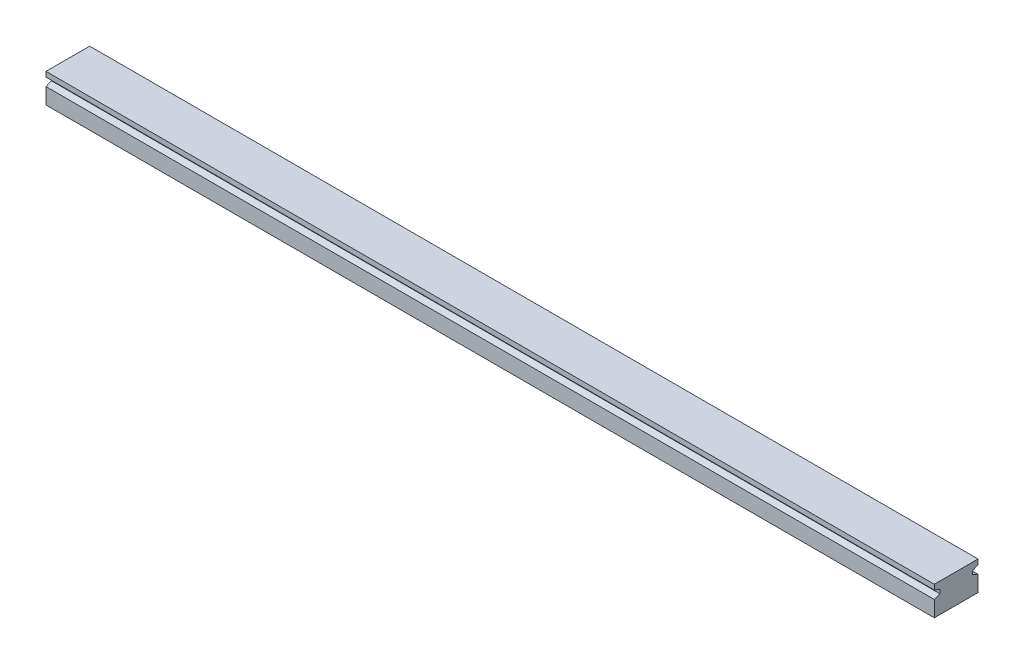
from build123d import *

# Parameters (mm, degrees)
SKETCH2_W           = 280
SKETCH2_H           = 12
SKETCH2_R           = 2
BOSS_EXTRUDE1_DEPTH = 4
CUT_EXTRUDE1_DEPTH  = 281
SKETCH5_R           = 2
BOSS_EXTRUDE2_DEPTH = 2
SKETCH4_W           = 18
SKETCH4_H           = 12
CUT_EXTRUDE2_DEPTH  = 9
BOSS_EXTRUDE3_REACH = 10
SKETCH7_R           = 2
SKETCH8_R           = 2
SKETCH8_R_2         = 1.5
BOSS_EXTRUDE4_DEPTH = 2


with BuildPart() as part:
    # Sketch2 → Boss-Extrude1 (new body, symmetric)
    with BuildSketch(Plane(origin=(0, 0, 0), x_dir=(1, 0, 0), z_dir=(0, 1, 0))):
        Rectangle(SKETCH2_W, SKETCH2_H)
        with Locations((-125, 0)):
            Circle(SKETCH2_R, mode=Mode.SUBTRACT)
        with Locations((-75, 0)):
            Circle(SKETCH2_R, mode=Mode.SUBTRACT)
        with Locations((-25, 0)):
            Circle(SKETCH2_R, mode=Mode.SUBTRACT)
        with Locations((25, 0)):
            Circle(SKETCH2_R, mode=Mode.SUBTRACT)
        with Locations((75, 0)):
            Circle(SKETCH2_R, mode=Mode.SUBTRACT)
        with Locations((125, 0)):
            Circle(SKETCH2_R, mode=Mode.SUBTRACT)
    extrude(amount=BOSS_EXTRUDE1_DEPTH, both=True)

    # Sketch3 → Cut-Extrude1 (cut, through all)
    with BuildSketch(Plane.ZY.offset(140)):
        Polygon((-6, 2.625), (-6, 0.375), (-4.5, 1), (-4.5, 2), align=None)
        Polygon((6, 2.625), (6, 0.375), (4.5, 1), (4.5, 2), align=None)
    extrude(amount=-CUT_EXTRUDE1_DEPTH, mode=Mode.SUBTRACT)

    # Sketch5 → Boss-Extrude2 (add)
    with BuildSketch(Plane(origin=(0, 4, 0), x_dir=(1, 0, 0), z_dir=(0, 1, 0))):
        with Locations((-75, 0)):
            Circle(SKETCH5_R)
        with Locations((-25, 0)):
            Circle(SKETCH5_R)
        with Locations((25, 0)):
            Circle(SKETCH5_R)
        with Locations((75, 0)):
            Circle(SKETCH5_R)
        with Locations((-125, 0)):
            Circle(SKETCH5_R)
        with Locations((125, 0)):
            Circle(SKETCH5_R)
    extrude(amount=-BOSS_EXTRUDE2_DEPTH)

    # Sketch4 → Cut-Extrude2 (cut, through all)
    with BuildSketch(Plane(origin=(0, 4, 0), x_dir=(1, 0, 0), z_dir=(0, 1, 0))):
        with Locations((-131, 0)):
            Rectangle(SKETCH4_W, SKETCH4_H)
    cut_extrude2 = extrude(amount=-CUT_EXTRUDE2_DEPTH, mode=Mode.SUBTRACT)

    # Mirror1: Cut-Extrude2 across plane
    add(cut_extrude2.mirror(Plane(origin=(0, 0, 0), x_dir=(0, 0, 1), z_dir=(1, 0, 0))), mode=Mode.SUBTRACT)

    # Sketch7 → Boss-Extrude3 (add, up to next)
    with BuildSketch(Plane.XZ.offset(4), mode=Mode.PRIVATE) as boss_extrude3_sk1:
        with Locations((-75, 0)):
            Circle(SKETCH7_R)
    boss_extrude3_tool1 = extrude(boss_extrude3_sk1.sketch, amount=-BOSS_EXTRUDE3_REACH, mode=Mode.PRIVATE) - part.part
    add(boss_extrude3_tool1.solids().sort_by_distance((-75, -4, 0))[0])
    # Sketch7 → Boss-Extrude3 (add, up to next)
    with BuildSketch(Plane.XZ.offset(4), mode=Mode.PRIVATE) as boss_extrude3_sk2:
        with Locations((75, 0)):
            Circle(SKETCH7_R)
    boss_extrude3_tool2 = extrude(boss_extrude3_sk2.sketch, amount=-BOSS_EXTRUDE3_REACH, mode=Mode.PRIVATE) - part.part
    add(boss_extrude3_tool2.solids().sort_by_distance((75, -4, 0))[0])

    # Sketch8 → Boss-Extrude4 (add)
    with BuildSketch(Plane.XZ.offset(-2)):
        with Locations((-25, 0)):
            Circle(SKETCH8_R)
        with Locations((-25, 0)):
            Circle(SKETCH8_R_2, mode=Mode.SUBTRACT)
        with Locations((25, 0)):
            Circle(SKETCH8_R)
        with Locations((25, 0)):
            Circle(SKETCH8_R_2, mode=Mode.SUBTRACT)
    extrude(amount=BOSS_EXTRUDE4_DEPTH)


solid = part.part
